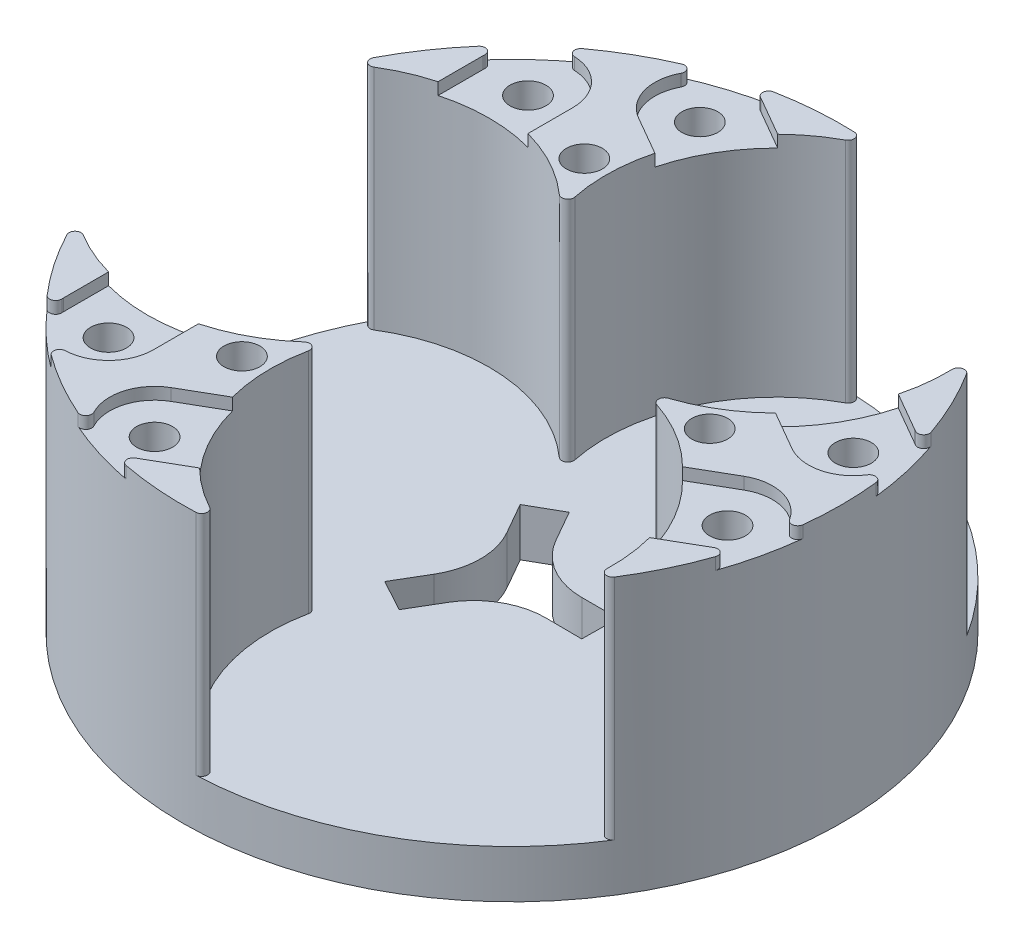
from build123d import *

# Parameters (mm, degrees)
SKETCH1_R           = 27.5
SKETCH1_R_2         = 1.5
BOSS_EXTRUDE1_DEPTH = 4
SKETCH2_R           = 1.5
BOSS_EXTRUDE2_DEPTH = 19
CUT_EXTRUDE1_DEPTH  = 1
SKETCH5_R           = 2.5
CUT_EXTRUDE2_DEPTH  = 3
FILLET1_R           = 0.5


with BuildPart() as part:
    # Sketch1 → Boss-Extrude1 (new body)
    with BuildSketch(Plane(origin=(0, 0, 0), x_dir=(1, 0, 0), z_dir=(0, 1, 0))):
        Circle(SKETCH1_R)
        with Locations((-16.165808, 17.5)):
            Circle(SKETCH1_R_2, mode=Mode.SUBTRACT)
        with Locations((-16.165808, -17.5)):
            Circle(SKETCH1_R_2, mode=Mode.SUBTRACT)
        with Locations((23.238348, 5.25)):
            Circle(SKETCH1_R_2, mode=Mode.SUBTRACT)
        with Locations((-7.072541, 22.75)):
            Circle(SKETCH1_R_2, mode=Mode.SUBTRACT)
        with Locations((-7.072541, -22.75)):
            Circle(SKETCH1_R_2, mode=Mode.SUBTRACT)
        with Locations((23.238348, -5.25)):
            Circle(SKETCH1_R_2, mode=Mode.SUBTRACT)
        with Locations((16.5, 0)):
            Circle(SKETCH1_R_2, mode=Mode.SUBTRACT)
        with Locations((-8.25, -14.289419)):
            Circle(SKETCH1_R_2, mode=Mode.SUBTRACT)
        with Locations((-8.25, 14.289419)):
            Circle(SKETCH1_R_2, mode=Mode.SUBTRACT)
        with BuildLine():
            Line((-3.443193, 3.010342), (-4.929187, 5.616454))
            Line((-4.929187, 5.616454), (-2.323074, 7.102448))
            Line((-2.323074, 7.102448), (-0.83708, 4.496335))
            ThreePointArc((-0.83708, 4.496335), (1.361532, 2.280053), (4.37598, 1.468323))
            Line((4.37598, 1.468323), (7.37598, 1.46874))
            Line((7.37598, 1.46874), (7.352905, -1.531171))
            Line((7.352905, -1.531171), (4.352993, -1.508096))
            ThreePointArc((4.352993, -1.508096), (1.35218, -2.285853), (-0.85992, -4.45758))
            Line((-0.85992, -4.45758), (-2.385089, -7.040962))
            Line((-2.385089, -7.040962), (-5.013824, -5.595365))
            Line((-5.013824, -5.595365), (-3.488655, -3.011984))
            ThreePointArc((-3.488655, -3.011984), (-2.655589, -0.006938), (-3.443193, 3.010342))
        make_face(mode=Mode.SUBTRACT)
    extrude(amount=BOSS_EXTRUDE1_DEPTH)

    # Sketch2 → Boss-Extrude2 (add)
    with BuildSketch(Plane(origin=(0, 4, 0), x_dir=(1, 0, 0), z_dir=(0, 1, 0))):
        with BuildLine():
            ThreePointArc((12.569039, 0.474576), (19.754447, 5.824575), (22.32713, 14.405594))
            ThreePointArc((22.32713, 14.405594), (22.68111, 14.89809), (23.249649, 14.686859))
            ThreePointArc((23.249649, 14.686859), (27.5, 0), (23.249649, -14.686859))
            ThreePointArc((23.249649, -14.686859), (22.68111, -14.89809), (22.32713, -14.405594))
            ThreePointArc((22.32713, -14.405594), (19.754447, -5.824575), (12.569039, -0.474576))
            ThreePointArc((12.569039, -0.474576), (12.226448, 0), (12.569039, 0.474576))
        make_face()
        with Locations((23.238348, 5.25)):
            Circle(SKETCH2_R, mode=Mode.SUBTRACT)
        with Locations((23.238348, -5.25)):
            Circle(SKETCH2_R, mode=Mode.SUBTRACT)
        with Locations((16.5, 0)):
            Circle(SKETCH2_R, mode=Mode.SUBTRACT)
        with BuildLine():
            ThreePointArc((-6.695515, -10.647819), (-6.113224, -10.588414), (-5.873525, -11.122396))
            ThreePointArc((-5.873525, -11.122396), (-4.832993, -20.020141), (1.312045, -26.538659))
            ThreePointArc((1.312045, -26.538659), (1.561569, -27.091463), (1.094369, -27.478216))
            ThreePointArc((1.094369, -27.478216), (-13.75, -23.815699), (-24.344018, -12.791357))
            ThreePointArc((-24.344018, -12.791357), (-24.24268, -12.193373), (-23.639176, -12.133065))
            ThreePointArc((-23.639176, -12.133065), (-14.921454, -14.195566), (-6.695515, -10.647819))
        make_face()
        with Locations((-7.072541, -22.75)):
            Circle(SKETCH2_R, mode=Mode.SUBTRACT)
        with Locations((-16.165808, -17.5)):
            Circle(SKETCH2_R, mode=Mode.SUBTRACT)
        with Locations((-8.25, -14.289419)):
            Circle(SKETCH2_R, mode=Mode.SUBTRACT)
        with BuildLine():
            ThreePointArc((-5.873525, 11.122396), (-6.113224, 10.588414), (-6.695515, 10.647819))
            ThreePointArc((-6.695515, 10.647819), (-14.921454, 14.195566), (-23.639176, 12.133065))
            ThreePointArc((-23.639176, 12.133065), (-24.24268, 12.193373), (-24.344018, 12.791357))
            ThreePointArc((-24.344018, 12.791357), (-13.75, 23.815699), (1.094369, 27.478216))
            ThreePointArc((1.094369, 27.478216), (1.561569, 27.091463), (1.312045, 26.538659))
            ThreePointArc((1.312045, 26.538659), (-4.832993, 20.020141), (-5.873525, 11.122396))
        make_face()
        with Locations((-16.165808, 17.5)):
            Circle(SKETCH2_R, mode=Mode.SUBTRACT)
        with Locations((-7.072541, 22.75)):
            Circle(SKETCH2_R, mode=Mode.SUBTRACT)
        with Locations((-8.25, 14.289419)):
            Circle(SKETCH2_R, mode=Mode.SUBTRACT)
    extrude(amount=BOSS_EXTRUDE2_DEPTH)

    # Sketch3 → Cut-Extrude1 (cut)
    with BuildSketch(Plane(origin=(0, 23, 0), x_dir=(1, 0, 0), z_dir=(0, 1, 0))):
        with BuildLine():
            Line((21.363348, -2.002405), (18.113785, -3.878541))
            Line((18.113785, -3.878541), (21.863785, -10.373732))
            Line((21.863785, -10.373732), (25.113348, -8.497595))
            ThreePointArc((25.113348, -8.497595), (26.485944, -3.375), (21.363348, -2.002405))
        make_face()
        with BuildLine():
            Line((25.113348, 8.497595), (21.863785, 10.373732))
            Line((21.863785, 10.373732), (18.113785, 3.878541))
            Line((18.113785, 3.878541), (21.363348, 2.002405))
            ThreePointArc((21.363348, 2.002405), (26.485944, 3.375), (25.113348, 8.497595))
        make_face()
        with BuildLine():
            Line((-19.915808, -13.747727), (-12.415808, -13.747727))
            Line((-12.415808, -13.747727), (-12.415808, -17.5))
            ThreePointArc((-12.415808, -17.5), (-16.165808, -21.25), (-19.915808, -17.5))
            Line((-19.915808, -17.5), (-19.915808, -13.747727))
        make_face()
        with BuildLine():
            Line((-5.697977, -17.626268), (-1.947977, -24.121459))
            Line((-1.947977, -24.121459), (-5.197541, -25.997595))
            ThreePointArc((-5.197541, -25.997595), (-10.320136, -24.625), (-8.947541, -19.502405))
            Line((-8.947541, -19.502405), (-5.697977, -17.626268))
        make_face()
        with BuildLine():
            Line((-1.947977, 24.121459), (-5.697977, 17.626268))
            Line((-5.697977, 17.626268), (-8.947541, 19.502405))
            ThreePointArc((-8.947541, 19.502405), (-10.320136, 24.625), (-5.197541, 25.997595))
            Line((-5.197541, 25.997595), (-1.947977, 24.121459))
        make_face()
        with BuildLine():
            Line((-12.415808, 13.747727), (-19.915808, 13.747727))
            Line((-19.915808, 13.747727), (-19.915808, 17.5))
            ThreePointArc((-19.915808, 17.5), (-16.165808, 21.25), (-12.415808, 17.5))
            Line((-12.415808, 17.5), (-12.415808, 13.747727))
        make_face()
    extrude(amount=-CUT_EXTRUDE1_DEPTH, mode=Mode.SUBTRACT)

    # Sketch5 → Cut-Extrude2 (cut)
    with BuildSketch(Plane.XZ):
        with Locations((-7.072541, 22.75)):
            Circle(SKETCH5_R)
        with Locations((-16.165808, 17.5)):
            Circle(SKETCH5_R)
        with Locations((23.238348, 5.25)):
            Circle(SKETCH5_R)
        with Locations((23.238348, -5.25)):
            Circle(SKETCH5_R)
        with Locations((-7.072541, -22.75)):
            Circle(SKETCH5_R)
        with Locations((-16.165808, -17.5)):
            Circle(SKETCH5_R)
        with Locations((16.5, 0)):
            Circle(SKETCH5_R)
        with Locations((-8.25, -14.289419)):
            Circle(SKETCH5_R)
        with Locations((-8.25, 14.289419)):
            Circle(SKETCH5_R)
    extrude(amount=-CUT_EXTRUDE2_DEPTH, mode=Mode.SUBTRACT)

    # Fillet1
    fillet1_edges = [part.edges().sort_by_distance(p)[0] for p in [
        (-7.399902, 22.5, -26.485684),
        (-8.920887, 22.5, -26.012839),
        (-8.920887, 22.5, 26.012839),
        (-7.399902, 22.5, 26.485684),
        (-19.237324, 22.5, 19.651345),
        (-18.067335, 22.5, 20.732134),
        (26.988223, 22.5, -5.280704),
        (26.637226, 22.5, -6.834339),
        (-18.067335, 22.5, -20.732134),
        (-19.237324, 22.5, -19.651345),
        (26.637226, 22.5, 6.834339),
        (26.988223, 22.5, 5.280704),
    ]]
    fillet(fillet1_edges, radius=FILLET1_R)


solid = part.part
